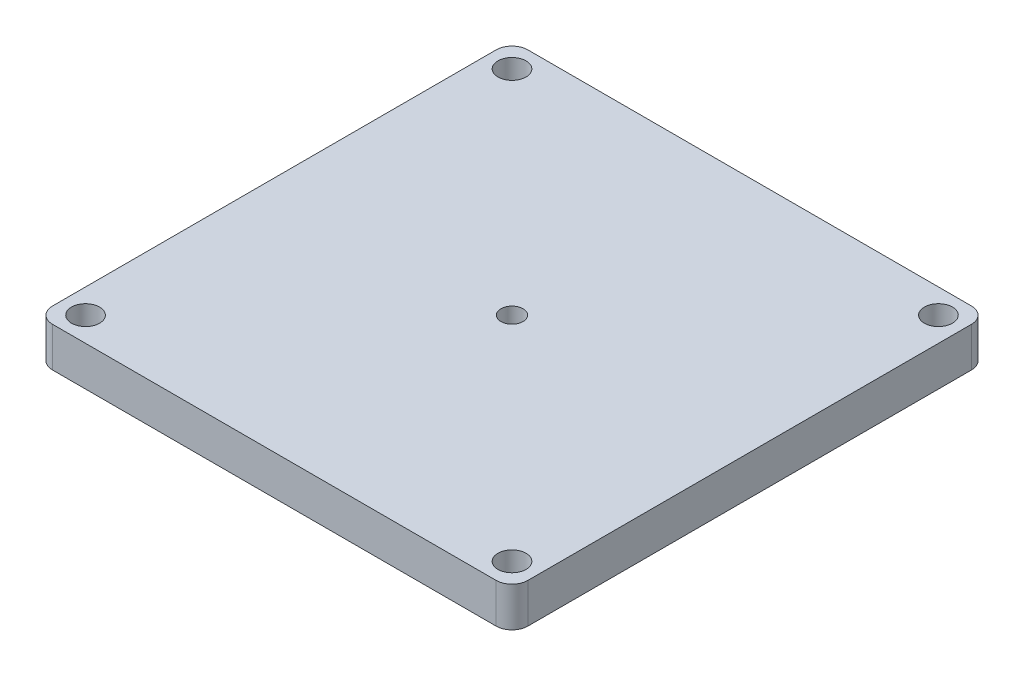
from build123d import *

# Parameters (mm, degrees)
SKETCH1_W                = 76.2
SKETCH1_H                = 76.2
BOSS_EXTRUDE1_DEPTH      = 6.35
FILLET1_R                = 2.54
SKETCH3_R                = 1.78
CUT_EXTRUDE1_DEPTH       = 7.35
SKETCH4_W                = 63.5
SKETCH4_H                = 63.5
BOSS_EXTRUDE2_DEPTH      = 2.54
FILLET2_R                = 2.54
M4_CLEARANCE_HOLE2_D     = 4.5
M4_CLEARANCE_HOLE2_DEPTH = 13.97
M4_CLEARANCE_HOLE2_TIP   = 1.351936393
SKETCH7_W                = 50.8
SKETCH7_H                = 3.81
CUT_EXTRUDE2_DEPTH       = 5.08
FILLET3_R                = 1.27


with BuildPart() as part:
    # Sketch1 → Boss-Extrude1 (new body)
    with BuildSketch(Plane(origin=(0, 0, 0), x_dir=(1, 0, 0), z_dir=(0, 1, 0))):
        Rectangle(SKETCH1_W, SKETCH1_H)
    extrude(amount=BOSS_EXTRUDE1_DEPTH)

    # Fillet1
    fillet1_edges = [part.edges().sort_by_distance(p)[0] for p in [
        (38.1, 3.175, 38.1),
        (-38.1, 3.175, 38.1),
        (-38.1, 3.175, -38.1),
        (38.1, 3.175, -38.1),
    ]]
    fillet(fillet1_edges, radius=FILLET1_R)

    # Sketch3 → Cut-Extrude1 (cut, through all)
    with BuildSketch(Plane(origin=(0, 6.35, 0), x_dir=(1, 0, 0), z_dir=(0, 1, 0))):
        Circle(SKETCH3_R)
    extrude(amount=-CUT_EXTRUDE1_DEPTH, mode=Mode.SUBTRACT)

    # Sketch4 → Boss-Extrude2 (add)
    with BuildSketch(Plane.XZ):
        Rectangle(SKETCH4_W, SKETCH4_H)
    extrude(amount=BOSS_EXTRUDE2_DEPTH)

    # Fillet2
    fillet2_edges = [part.edges().sort_by_distance(p)[0] for p in [
        (-31.75, -1.27, 31.75),
        (-31.75, -1.27, -31.75),
        (31.75, -1.27, -31.75),
        (31.75, -1.27, 31.75),
    ]]
    fillet(fillet2_edges, radius=FILLET2_R)

    # M4 Clearance Hole2
    with Locations(Plane.XZ.offset(2.54)):
        with Locations((-34.181051224, 34.181051224), (-34.181051224, -34.181051224), (34.181051224, -34.181051224), (34.181051224, 34.181051224)):
            Hole(M4_CLEARANCE_HOLE2_D / 2, depth=M4_CLEARANCE_HOLE2_DEPTH)
            with Locations((0, 0, -(M4_CLEARANCE_HOLE2_DEPTH + M4_CLEARANCE_HOLE2_TIP / 2))):  # 118° drill point
                Cone(0, M4_CLEARANCE_HOLE2_D / 2, M4_CLEARANCE_HOLE2_TIP, mode=Mode.SUBTRACT)

    # Sketch7 → Cut-Extrude2 (cut)
    with BuildSketch(Plane(origin=(0, -2.54, 0), x_dir=(-1, 0, 0), z_dir=(0, -1, 0))):
        with Locations((0, 27.94)):
            Rectangle(SKETCH7_W, SKETCH7_H)
        with Locations((0, -27.94)):
            Rectangle(SKETCH7_W, SKETCH7_H)
    extrude(amount=-CUT_EXTRUDE2_DEPTH, mode=Mode.SUBTRACT)

    # Fillet3
    fillet3_edges = [part.edges().sort_by_distance(p)[0] for p in [
        (25.4, 0, -26.035),
        (25.4, 0, -29.845),
        (-25.4, 0, -29.845),
        (-25.4, 0, -26.035),
        (25.4, 0, 29.845),
        (25.4, 0, 26.035),
        (-25.4, 0, 26.035),
        (-25.4, 0, 29.845),
    ]]
    fillet(fillet3_edges, radius=FILLET3_R)


solid = part.part
